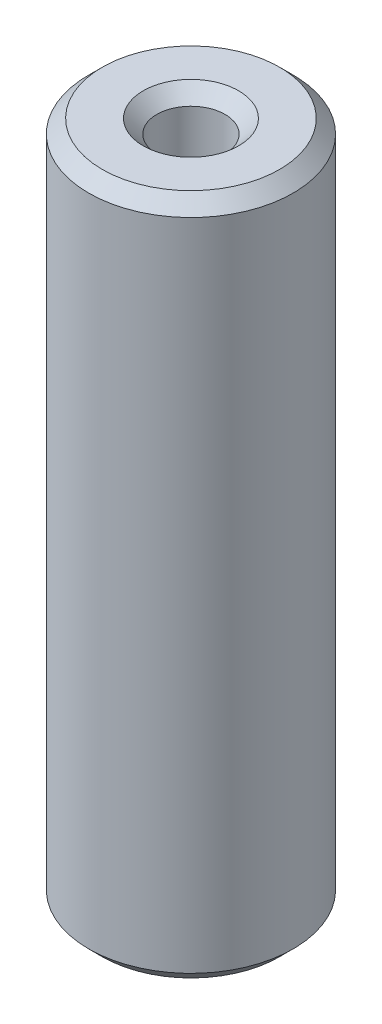
from build123d import *

# Parameters (mm, degrees)
ESQUISSE1_R      = 7.5
ESQUISSE1_R_2    = 2.5
EXTRUSION1_DEPTH = 50
CHANFREIN1_SIZE  = 1


with BuildPart() as part:
    # Esquisse1 → Extrusion1 (new body)
    with BuildSketch(Plane(origin=(0, 0, 0), x_dir=(1, 0, 0), z_dir=(0, 1, 0))):
        Circle(ESQUISSE1_R)
        Circle(ESQUISSE1_R_2, mode=Mode.SUBTRACT)
    extrude(amount=EXTRUSION1_DEPTH)

    # Chanfrein1
    chanfrein1_edges = [part.edges().sort_by_distance(p)[0] for p in [
        (-7.5, 0, 0),
        (-7.5, 50, 0),
        (-2.5, 0, 0),
        (-2.5, 50, 0),
    ]]
    chamfer(chanfrein1_edges, length=CHANFREIN1_SIZE)


solid = part.part
